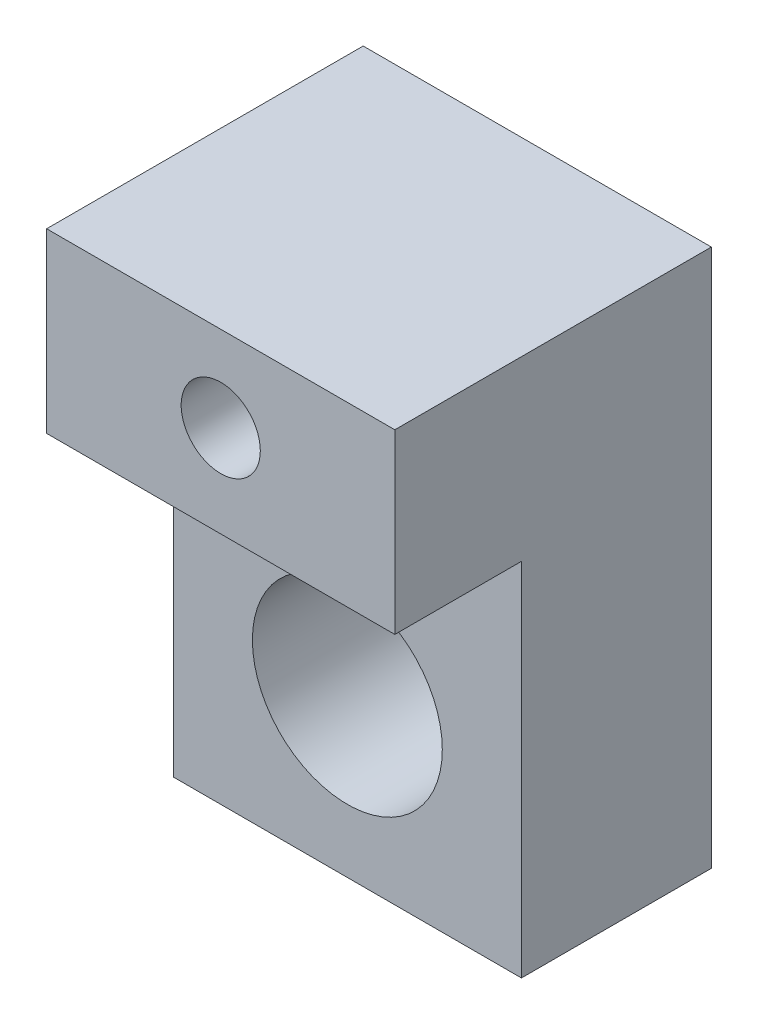
from build123d import *

# Parameters (mm, degrees)
SKETCH1_W                    = 5.5
SKETCH1_H                    = 8.5
BOSS_EXTRUDE1_DEPTH          = 3
SKETCH4_R                    = 1.5
CUT_EXTRUDE1_DEPTH           = 10
SKETCH7_W                    = 5.5
SKETCH7_H                    = 2.8
BOSS_EXTRUDE2_DEPTH          = 5
M1_6X0_35_TAPPED_HOLE1_D     = 1.25
M1_6X0_35_TAPPED_HOLE1_DEPTH = 4
M1_6X0_35_TAPPED_HOLE1_TIP   = 0.375537887


with BuildPart() as part:
    # Sketch1 → Boss-Extrude1 (new body)
    with BuildSketch(Plane.XY):
        Rectangle(SKETCH1_W, SKETCH1_H)
    extrude(amount=BOSS_EXTRUDE1_DEPTH)

    # Sketch4 → Cut-Extrude1 (cut)
    with BuildSketch(Plane.XY.offset(3)):
        with Locations((0, -1.75)):
            Circle(SKETCH4_R)
    extrude(amount=-CUT_EXTRUDE1_DEPTH, mode=Mode.SUBTRACT)

    # Sketch7 → Boss-Extrude2 (add)
    with BuildSketch(Plane(origin=(0, 0, 0), x_dir=(-1, 0, 0), z_dir=(0, 0, -1))):
        with Locations((0, 2.85)):
            Rectangle(SKETCH7_W, SKETCH7_H)
    extrude(amount=-BOSS_EXTRUDE2_DEPTH)

    # M1.6x0.35 Tapped Hole1
    with Locations(Plane.XY.offset(5)):
        with Locations((0, 2.9)):
            Hole(M1_6X0_35_TAPPED_HOLE1_D / 2, depth=M1_6X0_35_TAPPED_HOLE1_DEPTH)
            with Locations((0, 0, -(M1_6X0_35_TAPPED_HOLE1_DEPTH + M1_6X0_35_TAPPED_HOLE1_TIP / 2))):  # 118° drill point
                Cone(0, M1_6X0_35_TAPPED_HOLE1_D / 2, M1_6X0_35_TAPPED_HOLE1_TIP, mode=Mode.SUBTRACT)


solid = part.part
